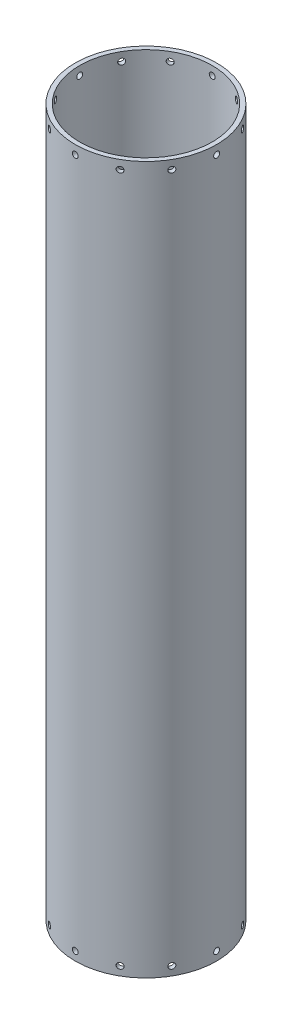
from build123d import *

# Parameters (mm, degrees)
SKETCH1_R                 = 76.2
SKETCH1_R_2               = 71.4375
INNER_OUTERDIAMETER_DEPTH = 762
SKETCH2_R                 = 3.175
TOP_BOTTOMBOLTHOLES_DEPTH = 77.2
CIRPATTERN1_COUNT         = 12


with BuildPart() as part:
    # Sketch1 → Inner&OuterDiameter (new body)
    with BuildSketch(Plane(origin=(0, 0, 0), x_dir=(1, 0, 0), z_dir=(0, 1, 0))):
        Circle(SKETCH1_R)
        Circle(SKETCH1_R_2, mode=Mode.SUBTRACT)
    extrude(amount=INNER_OUTERDIAMETER_DEPTH)

    # Sketch2 → Top&BottomBoltHoles (cut, through all)
    with BuildSketch(Plane.XY):
        with Locations((0, 752.475)):
            Circle(SKETCH2_R)
        with Locations((0, 9.525)):
            Circle(SKETCH2_R)
    top_bottomboltholes = extrude(amount=-TOP_BOTTOMBOLTHOLES_DEPTH, mode=Mode.SUBTRACT)

    # CirPattern1: Top&BottomBoltHoles ×12 about axis
    cirpattern1_axis = Axis((0, 762, 0), (0, -1, 0))
    for i in range(1, CIRPATTERN1_COUNT):
        add(top_bottomboltholes.rotate(cirpattern1_axis, i * 360 / CIRPATTERN1_COUNT), mode=Mode.SUBTRACT)


solid = part.part
